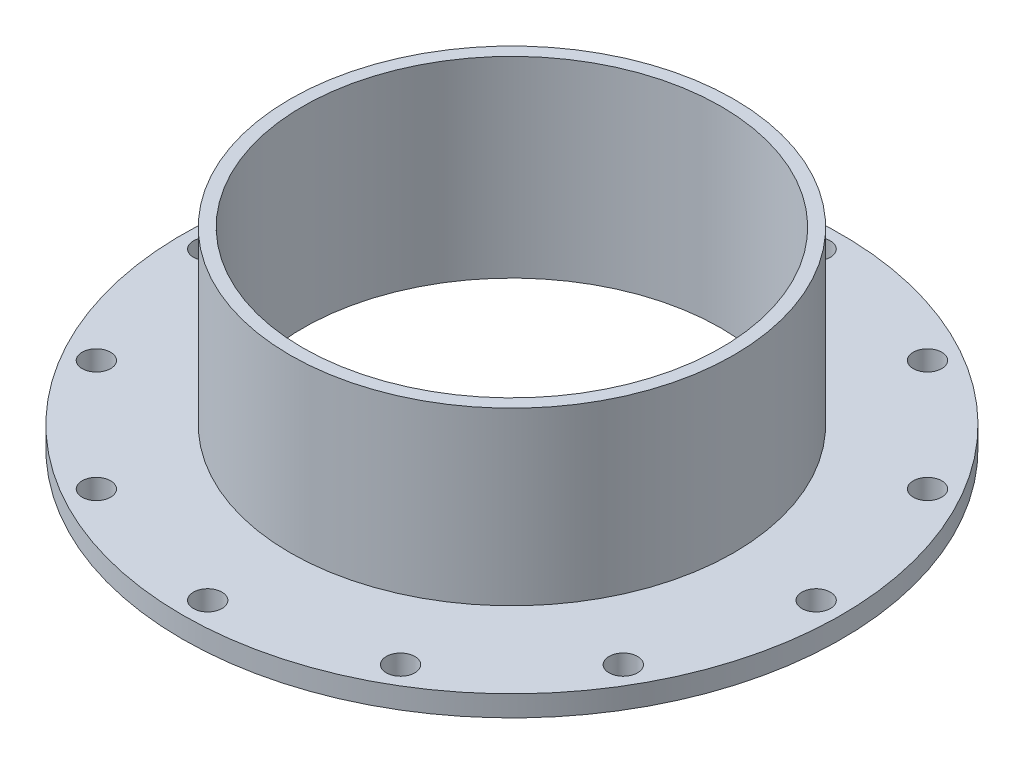
from build123d import *

# Parameters (mm, degrees)
SKETCH1_R           = 52
SKETCH1_R_2         = 33
BOSS_EXTRUDE1_DEPTH = 3.3
SKETCH2_R           = 35
SKETCH2_R_2         = 33
BOSS_EXTRUDE2_DEPTH = 27
SKETCH3_R           = 2.25
CUT_EXTRUDE1_DEPTH  = 4.3
CIRPATTERN1_COUNT   = 12


with BuildPart() as part:
    # Sketch1 → Boss-Extrude1 (new body)
    with BuildSketch(Plane(origin=(0, 0, 0), x_dir=(1, 0, 0), z_dir=(0, 1, 0))):
        Circle(SKETCH1_R)
        Circle(SKETCH1_R_2, mode=Mode.SUBTRACT)
    extrude(amount=BOSS_EXTRUDE1_DEPTH)

    # Sketch2 → Boss-Extrude2 (add)
    with BuildSketch(Plane(origin=(0, 3.3, 0), x_dir=(1, 0, 0), z_dir=(0, 1, 0))):
        Circle(SKETCH2_R)
        Circle(SKETCH2_R_2, mode=Mode.SUBTRACT)
    extrude(amount=BOSS_EXTRUDE2_DEPTH)

    # Sketch3 → Cut-Extrude1 (cut, through all)
    with BuildSketch(Plane(origin=(0, 3.3, 0), x_dir=(1, 0, 0), z_dir=(0, 1, 0))):
        with Locations((0, 48)):
            Circle(SKETCH3_R)
    cut_extrude1 = extrude(amount=-CUT_EXTRUDE1_DEPTH, mode=Mode.SUBTRACT)

    # CirPattern1: Cut-Extrude1 ×12 about axis
    cirpattern1_axis = Axis((0, 0, 0), (0, 1, 0))
    for i in range(1, CIRPATTERN1_COUNT):
        add(cut_extrude1.rotate(cirpattern1_axis, i * 360 / CIRPATTERN1_COUNT), mode=Mode.SUBTRACT)


solid = part.part
